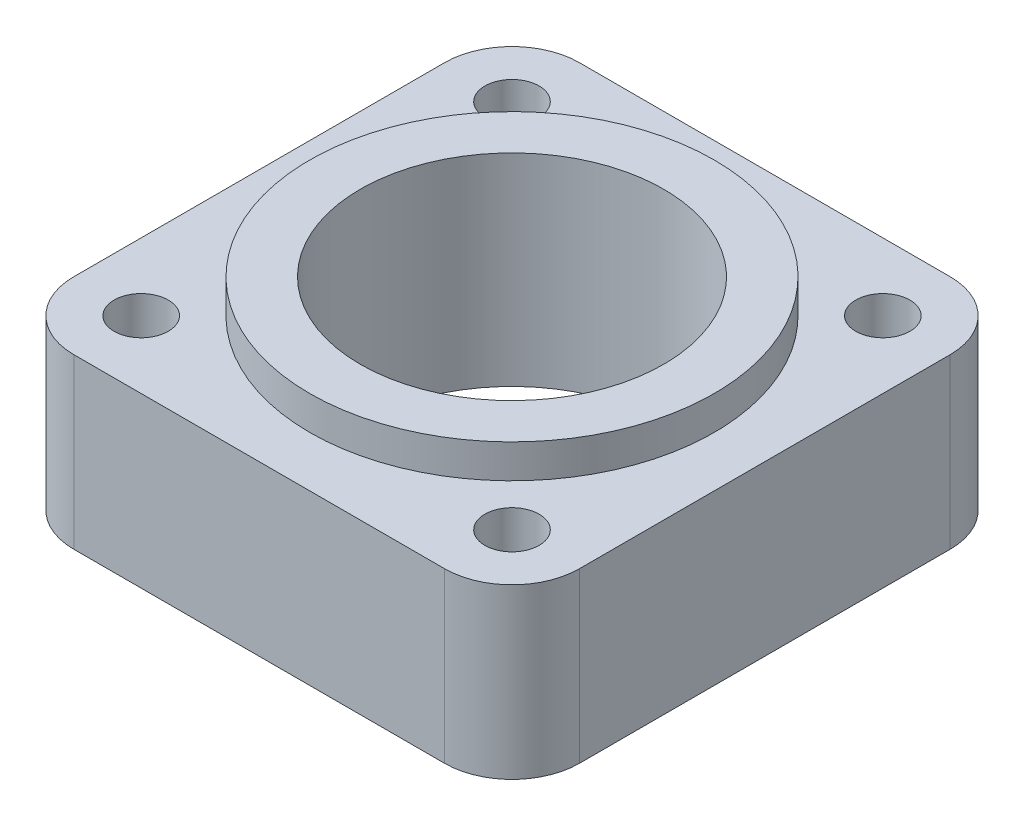
from build123d import *

# Parameters (mm, degrees)
SKETCH1_W               = 47.625
SKETCH1_H               = 47.625
BOSS_EXTRUDE1_DEPTH     = 15.875
SKETCH2_R               = 19.05
BOSS_EXTRUDE2_DEPTH     = 3.175
SKETCH3_R               = 14.2875
CUT_EXTRUDE1_DEPTH      = 20.05
F_1_4_20_TAPPED_HOLE1_D = 5.1054
FILLET1_R               = 6.35


with BuildPart() as part:
    # Sketch1 → Boss-Extrude1 (new body)
    with BuildSketch(Plane(origin=(0, 0, 0), x_dir=(1, 0, 0), z_dir=(0, 1, 0))):
        Rectangle(SKETCH1_W, SKETCH1_H)
    extrude(amount=BOSS_EXTRUDE1_DEPTH)

    # Sketch2 → Boss-Extrude2 (add)
    with BuildSketch(Plane(origin=(0, 15.875, 0), x_dir=(1, 0, 0), z_dir=(0, 1, 0))):
        Circle(SKETCH2_R)
    extrude(amount=BOSS_EXTRUDE2_DEPTH)

    # Sketch3 → Cut-Extrude1 (cut, through all)
    with BuildSketch(Plane(origin=(0, 19.05, 0), x_dir=(1, 0, 0), z_dir=(0, 1, 0))):
        Circle(SKETCH3_R)
    extrude(amount=-CUT_EXTRUDE1_DEPTH, mode=Mode.SUBTRACT)

    # 1/4-20 Tapped Hole1 (through all)
    with Locations(Plane(origin=(0, 15.875, 0), x_dir=(1, 0, 0), z_dir=(0, 1, 0))):
        with Locations((-17.4625, 17.4625), (17.4625, 17.4625), (17.4625, -17.4625), (-17.4625, -17.4625)):
            Hole(F_1_4_20_TAPPED_HOLE1_D / 2)

    # Fillet1
    fillet1_edges = [part.edges().sort_by_distance(p)[0] for p in [
        (-23.8125, 7.9375, -23.8125),
        (23.8125, 7.9375, -23.8125),
        (23.8125, 7.9375, 23.8125),
        (-23.8125, 7.9375, 23.8125),
    ]]
    fillet(fillet1_edges, radius=FILLET1_R)


solid = part.part
